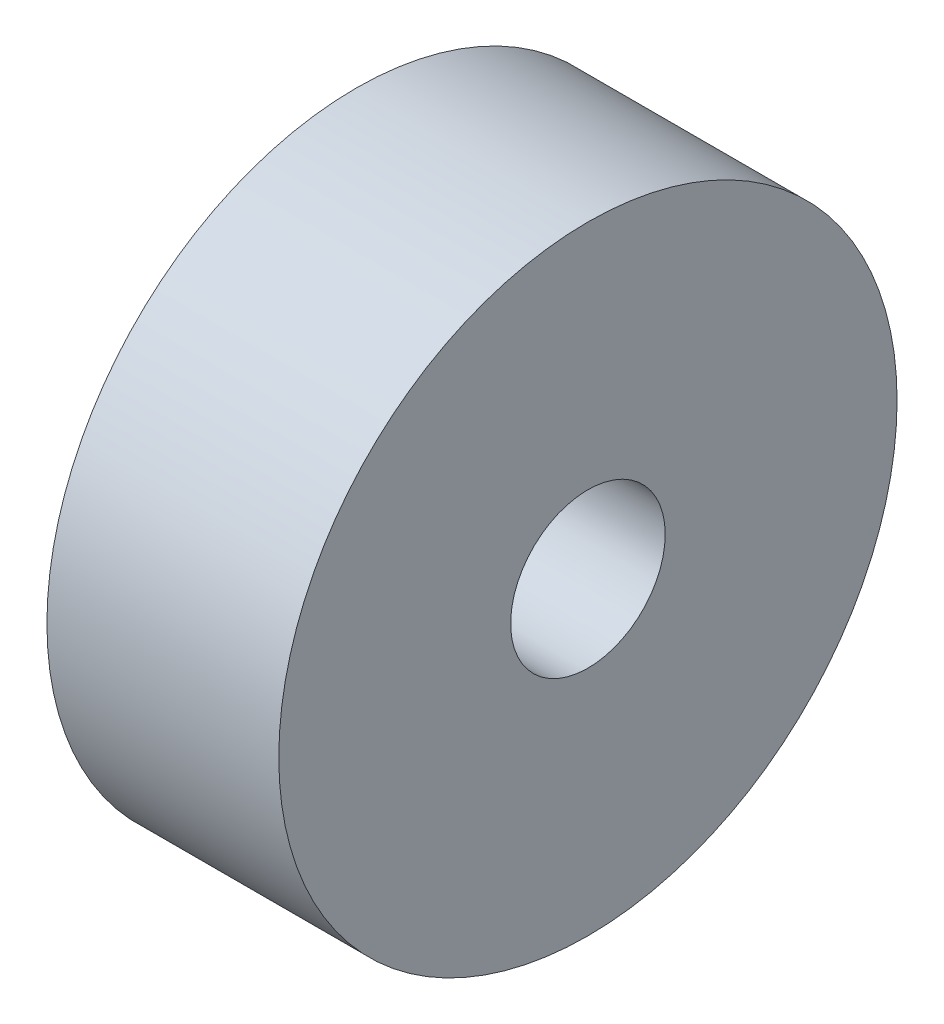
from build123d import *

# Parameters (mm, degrees)
SKETCH1_R           = 101.6
SKETCH1_R_2         = 25.4
BOSS_EXTRUDE1_DEPTH = 76.2


with BuildPart() as part:
    # Sketch1 → Boss-Extrude1 (new body)
    with BuildSketch(Plane(origin=(0, 0, 0), x_dir=(0, 0, -1), z_dir=(1, 0, 0))):
        Circle(SKETCH1_R)
        Circle(SKETCH1_R_2, mode=Mode.SUBTRACT)
    extrude(amount=BOSS_EXTRUDE1_DEPTH)


solid = part.part
